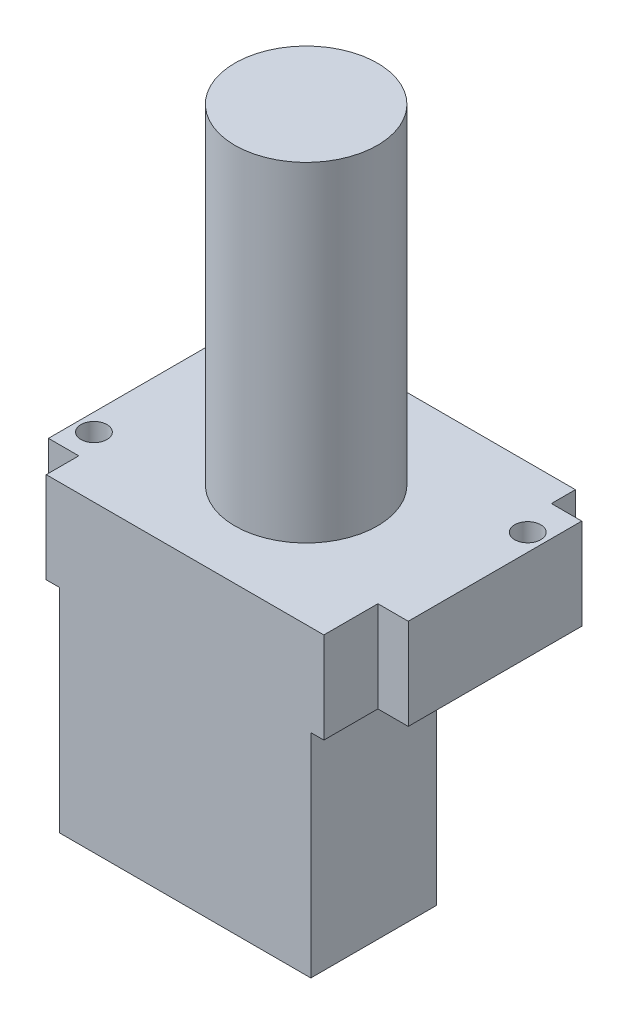
from build123d import *

# Parameters (mm, degrees)
SKETCH_1_W          = 29
SKETCH_1_H          = 14.5
EXTRUDE_1_DEPTH     = 24.5
SKETCH_3_W          = 32
SKETCH_3_H          = 29
EXTRUDE_3_DEPTH     = 10.5
SKETCH_6_W          = 20
SKETCH_6_H          = 10.5
EXTRUDE_5_DEPTH     = 3.5
SKETCH_8_W          = 20
SKETCH_8_H          = 10.5
EXTRUDE_6_DEPTH     = 3.5
SKETCH_9_R          = 1.5
CUT_EXTRUDE_1_DEPTH = 36
SKETCH_11_R         = 8.217115379
EXTRUDE_7_DEPTH     = 38


with BuildPart() as part:
    # 草圖1 → 填料-伸長1 (new body)
    with BuildSketch(Plane(origin=(0, 0, 0), x_dir=(1, 0, 0), z_dir=(0, 1, 0))):
        Rectangle(SKETCH_1_W, SKETCH_1_H)
    extrude(amount=EXTRUDE_1_DEPTH)

    # 草圖3 → 填料-伸長3 (add)
    with BuildSketch(Plane(origin=(0, 24.5, 0), x_dir=(1, 0, 0), z_dir=(0, 1, 0))):
        with Locations((0, 7.25)):
            Rectangle(SKETCH_3_W, SKETCH_3_H)
    extrude(amount=EXTRUDE_3_DEPTH)

    # 草圖6 → 填料-伸長5 (add)
    with BuildSketch(Plane(origin=(16, 0, 0), x_dir=(0, 0, -1), z_dir=(1, 0, 0))):
        with Locations((8.978907639, 29.75)):
            Rectangle(SKETCH_6_W, SKETCH_6_H)
    extrude(amount=EXTRUDE_5_DEPTH)

    # 草圖8 → 填料-伸長6 (add)
    with BuildSketch(Plane.ZY.offset(16)):
        with Locations((-6.503080988, 29.75)):
            Rectangle(SKETCH_8_W, SKETCH_8_H)
    extrude(amount=EXTRUDE_6_DEPTH)

    # 草圖9 → 除料-伸長1 (cut, through all)
    with BuildSketch(Plane(origin=(0, 35, 0), x_dir=(1, 0, 0), z_dir=(0, 1, 0))):
        with Locations((17.5, 14.75)):
            Circle(SKETCH_9_R)
        with Locations((-17.5, -0.25)):
            Circle(SKETCH_9_R)
    extrude(amount=-CUT_EXTRUDE_1_DEPTH, mode=Mode.SUBTRACT)

    # 草圖11 → 填料-伸長7 (add)
    with BuildSketch(Plane(origin=(0, 35, 0), x_dir=(1, 0, 0), z_dir=(0, 1, 0))):
        with Locations((0, 6.709500823)):
            Circle(SKETCH_11_R)
    extrude(amount=EXTRUDE_7_DEPTH)


solid = part.part
